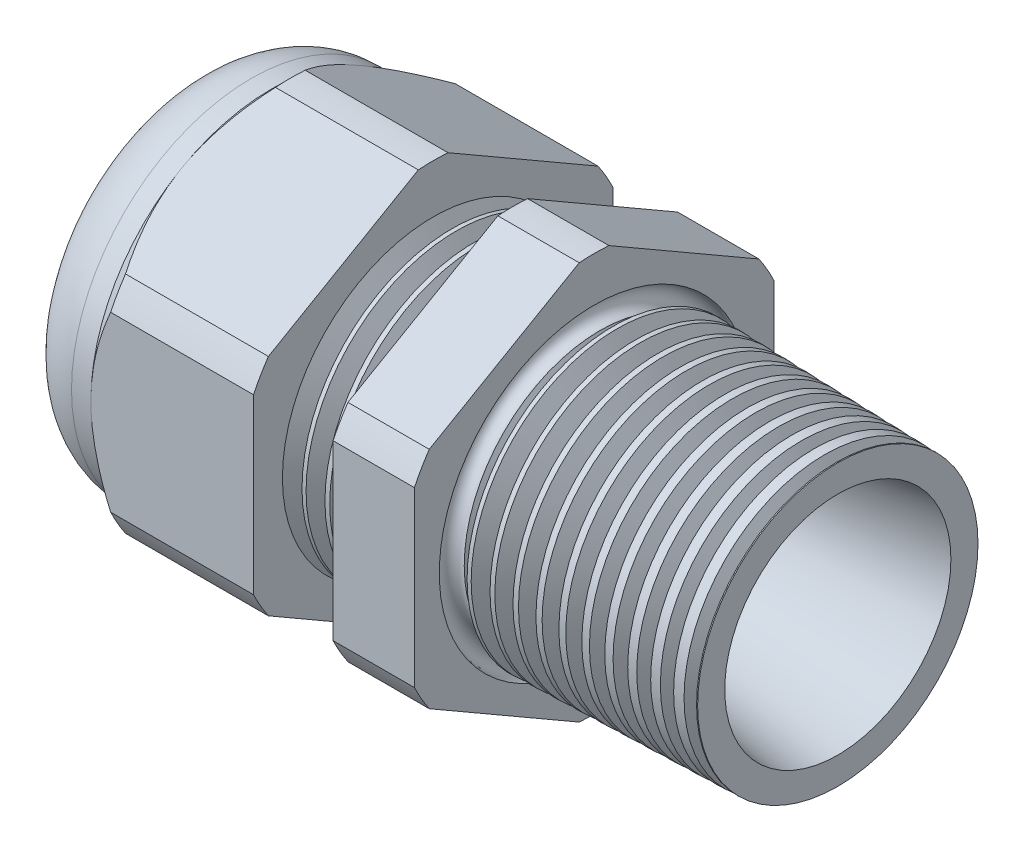
from build123d import *

# Parameters (mm, degrees)
LPATTERN6_COUNT    = 4
LPATTERN6_PITCH    = 1.397
LPATTERN7_COUNT    = 11
LPATTERN7_PITCH    = 1.397
SKETCH12_OUTSIDE_W = 61.024
SKETCH12_OUTSIDE_H = 61.024
CUT_EXTRUDE2_DEPTH = 35.878
FILLET4_R          = 3.81
SKETCH19_OUTSIDE_W = 38.452
SKETCH19_OUTSIDE_H = 40.882
SKETCH19_OUTSIDE_R = 11.049
CUT_EXTRUDE3_DEPTH = 1.999996
CUT_EXTRUDE3_DRAFT = -45
SKETCH28_R         = 0.635


with BuildPart() as part:
    # Sketch10 → Revolve2 (revolve)
    with BuildSketch(Plane.XY, mode=Mode.PRIVATE) as revolve2_sk:
        Polygon((-27.766, 3.429), (-17.766, 3.429), (7.112, 6.95325), (7.112, 8.619546643), (-7.874, 9.011968864), (-7.874, 22.098), (-12.874, 22.098), (-12.874, 9.142898472), (-17.766, 9.271), (-17.766, 22.098), (-27.766, 22.098), (-27.766, 11.049), (-32.766, 11.049), (-32.766, 6.95325), (-27.766, 6.95325), align=None)
    revolve(revolve2_sk.sketch.rotate(Axis((0, 0, 0), (-1, 0, 0)), 90), axis=Axis((0, 0, 0), (-1, 0, 0)))  # turned: the seam where the file's is

    # Sketch26 → Cut-Revolve1 (revolve, cut)
    with BuildSketch(Plane.XY, mode=Mode.PRIVATE) as cut_revolve1_sk:
        Polygon((-17.766, 9.271), (-16.593226271, 9.240289839), (-17.206208915, 8.239993077), align=None)
    cut_revolve1 = revolve(cut_revolve1_sk.sketch.rotate(Axis((0, 0, 0), (-1, 0, 0)), 90), axis=Axis((0, 0, 0), (-1, 0, 0)), mode=Mode.SUBTRACT)  # turned: the seam where the file's is

    # LPattern6: Cut-Revolve1 ×4
    with Locations(*[(i * LPATTERN6_PITCH, 0, 0) for i in range(1, LPATTERN6_COUNT)]):
        add(cut_revolve1, mode=Mode.SUBTRACT)

    # Sketch27 → Cut-Revolve2 (revolve, cut)
    with BuildSketch(Plane.XY, mode=Mode.PRIVATE) as cut_revolve2_sk:
        Polygon((-7.874, 9.011968864), (-6.701226271, 8.981258703), (-7.314208915, 7.980961941), align=None)
    cut_revolve2 = revolve(cut_revolve2_sk.sketch.rotate(Axis((0, 0, 0), (-1, 0, 0)), 90), axis=Axis((0, 0, 0), (-1, 0, 0)), mode=Mode.SUBTRACT)  # turned: the seam where the file's is

    # LPattern7: Cut-Revolve2 ×11
    with Locations(*[(i * LPATTERN7_PITCH, 0, 0) for i in range(1, LPATTERN7_COUNT)]):
        add(cut_revolve2, mode=Mode.SUBTRACT)

    # Sketch12 outside → Cut-Extrude2 (cut, through all)
    with BuildSketch(Plane.ZY.offset(27.766)):
        Rectangle(SKETCH12_OUTSIDE_W, SKETCH12_OUTSIDE_H)
        with BuildLine():
            Line((-0.914603493, 12.230239676), (-10.134396507, 6.907189697))
            ThreePointArc((-10.134396507, 6.907189697), (-10.621273302, 6.132195), (-11.049, 5.323049978))
            Line((-11.049, 5.323049978), (-11.049, -5.323049978))
            ThreePointArc((-11.049, -5.323049978), (-10.621273302, -6.132195), (-10.134396507, -6.907189697))
            Line((-10.134396507, -6.907189697), (-0.914603493, -12.230239676))
            ThreePointArc((-0.914603493, -12.230239676), (0, -12.26439), (0.914603493, -12.230239676))
            Line((0.914603493, -12.230239676), (10.134396507, -6.907189697))
            ThreePointArc((10.134396507, -6.907189697), (10.621273302, -6.132195), (11.049, -5.323049978))
            Line((11.049, -5.323049978), (11.049, 5.323049978))
            ThreePointArc((11.049, 5.323049978), (10.621273302, 6.132195), (10.134396507, 6.907189697))
            Line((10.134396507, 6.907189697), (0.914603493, 12.230239676))
            ThreePointArc((0.914603493, 12.230239676), (0, 12.26439), (-0.914603493, 12.230239676))
        make_face(mode=Mode.SUBTRACT)
    extrude(amount=-CUT_EXTRUDE2_DEPTH, mode=Mode.SUBTRACT)

    # Fillet4
    fillet4_edges = [part.edges().sort_by_distance(p)[0] for p in [
        (-32.766, 0, 11.049),
    ]]
    fillet(fillet4_edges, radius=FILLET4_R)


with BuildPart() as body_2:
    # Sketch30 → Revolve8 (revolve)
    with BuildSketch(Plane.XY, mode=Mode.PRIVATE) as revolve8_sk:
        with BuildLine():
            Line((-31.7754, 6.95325), (-27.766, 6.95325))
            Line((-27.766, 6.95325), (-27.766, 3.429))
            Line((-27.766, 3.429), (-32.004, 3.429))
            Line((-32.004, 3.429), (-32.004, 6.72465))
            ThreePointArc((-32.004, 6.72465), (-31.93704461, 6.88629461), (-31.7754, 6.95325))
        make_face()
    revolve(revolve8_sk.sketch.rotate(Axis((0, 0, 0), (-1, 0, 0)), 270), axis=Axis((0, 0, 0), (-1, 0, 0)))  # turned: the seam where the file's is


with BuildPart() as cut_extrude3_tool:
    # Sketch19 outside → Cut-Extrude3 (with draft: the straight prism first)
    with BuildSketch(Plane.ZY.offset(27.766)):
        Rectangle(SKETCH19_OUTSIDE_W, SKETCH19_OUTSIDE_H)
        Circle(SKETCH19_OUTSIDE_R, mode=Mode.SUBTRACT)
    extrude(amount=-CUT_EXTRUDE3_DEPTH)
    # Cut-Extrude3: the draft: its side faces are tilted about the plane it starts from
    cut_extrude3_sides = [cut_extrude3_tool.faces().sort_by_distance(p)[0] for p in [
        (-26.766002, -20.441, 0),
        (-26.766002, 0, 19.226),
        (-26.766002, 20.441, 0),
        (-26.766002, 0, -19.226),
        (-26.766002, 0, -11.049),
    ]]
    draft(cut_extrude3_sides, Plane.ZY.offset(27.766), CUT_EXTRUDE3_DRAFT)


with BuildPart() as part_1:
    add(part.part)

    # Cut-Extrude3: cut by cut_extrude3_tool
    add(cut_extrude3_tool.part, mode=Mode.SUBTRACT)

    # Sketch28 → Cut-Revolve3 (revolve, cut)
    with BuildSketch(Plane.XY, mode=Mode.PRIVATE) as cut_revolve3_sk:
        with Locations((-7.8486, -8.884968864)):
            Circle(SKETCH28_R)
    revolve(cut_revolve3_sk.sketch.rotate(Axis((7.112, 0, 0), (-1, 0, 0)), 90), axis=Axis((7.112, 0, 0), (-1, 0, 0)), mode=Mode.SUBTRACT)  # turned: the seam where the file's is


solid = Compound([body_2.part, part_1.part])
